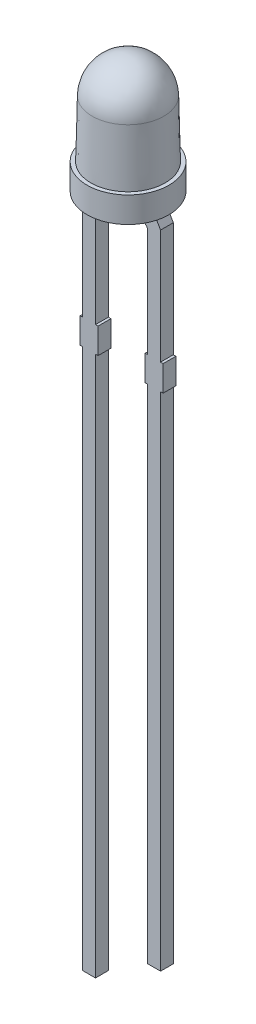
from build123d import *

# Parameters (mm, degrees)
SKETCH1_W          = 1.6
SKETCH1_H          = 1
EXTRUDE1_DEPTH     = 0.25
FILLET1_R          = 0.2
CUT_EXTRUDE1_DEPTH = 0.01


with BuildPart() as part:
    # Sketch1 → Revolve1 (revolve)
    with BuildSketch(Plane.XY, mode=Mode.PRIVATE) as revolve1_sk:
        with Locations((0.8, 0.5)):
            Rectangle(SKETCH1_W, SKETCH1_H)
    revolve(revolve1_sk.sketch.rotate(Axis((0, 1, 0), (0, 1, 0)), 90), axis=Axis((0, 1, 0), (0, 1, 0)))  # turned: the seam where the file's is

    # Sketch1_3 → Revolve2 (revolve)
    with BuildSketch(Plane.XY, mode=Mode.PRIVATE) as revolve2_sk:
        with BuildLine():
            Line((0, 4.6), (0, 1))
            Line((0, 1), (1.45, 1))
            Line((1.45, 1), (1.399643702, 3.231583349))
            ThreePointArc((1.399643702, 3.231583349), (0.978719396, 4.201053617), (0, 4.6))
        make_face()
    revolve(revolve2_sk.sketch.rotate(Axis((0, 1, 0), (0, 1, 0)), 90), axis=Axis((0, 1, 0), (0, 1, 0)))  # turned: the seam where the file's is

    # Sketch1_4 → Extrude1 (add, symmetric)
    with BuildSketch(Plane.XY):
        Polygon((1.27, 0), (0.42, 0), (0.42, -0.5), (1.02, -0.5), (1.02, -4.9), (0.92, -4.9), (0.92, -5.9), (1.02, -5.9), (1.02, -25.5), (1.52, -25.5), (1.52, -5.9), (1.62, -5.9), (1.62, -4.9), (1.52, -4.9), (1.52, -0.433012702), align=None)
        Polygon((-1.27, 0), (-1.52, -0.433012702), (-1.52, -4.9), (-1.62, -4.9), (-1.62, -5.9), (-1.52, -5.9), (-1.52, -27), (-1.02, -27), (-1.02, -5.9), (-0.92, -5.9), (-0.92, -4.9), (-1.02, -4.9), (-1.02, -0.5), (-0.42, -0.5), (-0.42, 0), align=None)
    extrude(amount=EXTRUDE1_DEPTH, both=True)

    # Fillet1
    fillet1_edges = [part.edges().sort_by_distance(p)[0] for p in [
        (1.02, -0.5, 0),
        (-1.02, -0.5, 0),
    ]]
    fillet(fillet1_edges, radius=FILLET1_R)

    # Sketch2 → Cut-Extrude1 (cut)
    with BuildSketch(Plane.XZ):
        Polygon((-0.609959979, -0.858665099), (-0.634742416, -0.93313108), (-0.660236878, -0.93261684), (-0.674477384, -0.881746587), (-0.690557289, -0.931983928), (-0.716387985, -0.931430131), (-0.737847637, -0.855995004), (-0.712610295, -0.856529023), (-0.700861878, -0.908447536), (-0.68377327, -0.857122378), (-0.662491624, -0.857577283), (-0.648330232, -0.909555131), (-0.634643523, -0.858150859), align=None)
        Polygon((-0.475812322, -0.861481362), (-0.500594759, -0.935947343), (-0.526089221, -0.935433102), (-0.540329727, -0.884562849), (-0.556409633, -0.934800191), (-0.582240329, -0.934246394), (-0.603699981, -0.858811267), (-0.578462639, -0.859345286), (-0.566714221, -0.911263799), (-0.549625614, -0.85993864), (-0.528343968, -0.860393545), (-0.514182576, -0.912371394), (-0.500495867, -0.860967121), align=None)
        Polygon((-0.341664666, -0.864297625), (-0.366447103, -0.938763606), (-0.391941565, -0.938249365), (-0.406182071, -0.887379112), (-0.422261976, -0.937616454), (-0.448092672, -0.937062656), (-0.469552324, -0.86162753), (-0.444314982, -0.862161549), (-0.432566565, -0.914080061), (-0.415477957, -0.862754903), (-0.394196312, -0.863209808), (-0.380034919, -0.915187656), (-0.36634821, -0.863783384), align=None)
        Polygon((-0.302789952, -0.940116261), (-0.327750396, -0.93960202), (-0.327196598, -0.913375754), (-0.302236155, -0.913889995), align=None)
        with BuildLine():
            add(Edge.make_bspline(
                [(-0.197717758, -0.911049585), (-0.197782236, -0.91224581), (-0.197908918, -0.914596065), (-0.198573487, -0.918025605), (-0.199627114, -0.921272317), (-0.20106367, -0.924340316), (-0.202871036, -0.927233419), (-0.205102667, -0.929920168), (-0.207700807, -0.932435028), (-0.210673682, -0.934745096), (-0.213971897, -0.936808214), (-0.217549415, -0.938618021), (-0.221401879, -0.940128274), (-0.225542786, -0.941292086), (-0.229938541, -0.942238753), (-0.234616239, -0.942830126), (-0.239557674, -0.943152009), (-0.242937477, -0.94313765), (-0.244671872, -0.943130281)],
                knots=[0, 0, 0, 0, 0.902626255, 1.77341389, 2.625621169, 3.470867019, 4.322029356, 5.191012395, 6.098187291, 7.044037616, 8.024852535, 9.027688581, 10.063639126, 11.139989839, 12.268247324, 13.451727298, 14.692317139, 16, 16, 16, 16], degree=3))
            add(Edge.make_bspline(
                [(-0.244671872, -0.943130281), (-0.24666437, -0.943068119), (-0.250517629, -0.942947904), (-0.256093043, -0.942389353), (-0.261279139, -0.941655981), (-0.266090007, -0.940576415), (-0.270617421, -0.939316959), (-0.274949447, -0.937897639), (-0.279159699, -0.93639654), (-0.281873988, -0.935239113), (-0.283220132, -0.934665091)],
                knots=[0, 0, 0, 0, 1.203405388, 2.32724652, 3.381787046, 4.364159093, 5.302027002, 6.21856218, 7.116500868, 8, 8, 8, 8], degree=3))
            Line((-0.283220132, -0.934665091), (-0.28272567, -0.910832021))
            Line((-0.28272567, -0.910832021), (-0.279917125, -0.910891357))
            add(Edge.make_bspline(
                [(-0.279917125, -0.910891357), (-0.278589886, -0.911937762), (-0.275937594, -0.914028851), (-0.271634449, -0.916729081), (-0.267107649, -0.919098273), (-0.262380378, -0.921075796), (-0.257571373, -0.92263769), (-0.25280923, -0.923820056), (-0.248123936, -0.924584697), (-0.245017365, -0.924725957), (-0.243485163, -0.924795629)],
                knots=[0, 0, 0, 0, 1.021384829, 2.041087774, 3.066386267, 4.108115676, 5.135581984, 6.120851118, 7.073179481, 8, 8, 8, 8], degree=3))
            add(Edge.make_bspline(
                [(-0.243485163, -0.924795629), (-0.243063195, -0.924798103), (-0.242159738, -0.924803402), (-0.240715596, -0.924757454), (-0.239086167, -0.924681946), (-0.237331902, -0.924544609), (-0.235565984, -0.924369752), (-0.233918718, -0.924081442), (-0.23243575, -0.923771908), (-0.231529936, -0.923459297), (-0.231103834, -0.923312243)],
                knots=[0, 0, 0, 0, 0.808443433, 1.730920239, 2.767970038, 3.933466555, 5.10244901, 6.165709291, 7.137136634, 8, 8, 8, 8], degree=3))
            add(Edge.make_bspline(
                [(-0.231103834, -0.923312243), (-0.230625557, -0.923115789), (-0.229691479, -0.922732114), (-0.22839409, -0.922042928), (-0.227223764, -0.921281436), (-0.226181525, -0.920439281), (-0.225286557, -0.919427868), (-0.224655286, -0.918178199), (-0.224280257, -0.916707237), (-0.224215673, -0.915660311), (-0.224181366, -0.915104173)],
                knots=[0, 0, 0, 0, 1.072964233, 2.09550425, 3.044592356, 3.968169394, 4.870818602, 5.825810278, 6.845047034, 8, 8, 8, 8], degree=3))
            add(Edge.make_bspline(
                [(-0.224181366, -0.915104173), (-0.224202738, -0.914573245), (-0.224244813, -0.91352799), (-0.224744797, -0.912006882), (-0.225630302, -0.910627571), (-0.226838592, -0.909348567), (-0.228388348, -0.908207917), (-0.230247355, -0.907176002), (-0.232435299, -0.906291159), (-0.234025924, -0.905844963), (-0.234861746, -0.905610502)],
                knots=[0, 0, 0, 0, 0.82308457, 1.620432243, 2.453727675, 3.352874885, 4.340918783, 5.432996612, 6.651123416, 8, 8, 8, 8], degree=3))
            add(Edge.make_bspline(
                [(-0.234861746, -0.905610502), (-0.236770642, -0.90512886), (-0.240688567, -0.904140313), (-0.246664602, -0.902905728), (-0.25261407, -0.901537722), (-0.25643538, -0.900260415), (-0.258299246, -0.899637401)],
                knots=[0, 0, 0, 0, 0.976031335, 2.003260101, 3.026078686, 4, 4, 4, 4], degree=3))
            add(Edge.make_bspline(
                [(-0.258299246, -0.899637401), (-0.259305489, -0.899272164), (-0.261264008, -0.89856128), (-0.264054855, -0.897348257), (-0.266634862, -0.89607463), (-0.268982382, -0.894686164), (-0.271094939, -0.893199022), (-0.273014475, -0.891656817), (-0.274707503, -0.890016583), (-0.276154364, -0.888259688), (-0.27741752, -0.886418537), (-0.278497588, -0.884483638), (-0.279429934, -0.882454015), (-0.280118188, -0.88030105), (-0.280713527, -0.878069269), (-0.28107579, -0.875722624), (-0.2812768, -0.873283041), (-0.28128014, -0.871624879), (-0.281281841, -0.870780597)],
                knots=[0, 0, 0, 0, 1.283776869, 2.498700329, 3.648104778, 4.733106613, 5.766444026, 6.744627296, 7.684133326, 8.588328419, 9.470112962, 10.358820773, 11.243685085, 12.14396387, 13.066542897, 14.011723146, 14.987634136, 16, 16, 16, 16], degree=3))
            add(Edge.make_bspline(
                [(-0.281281841, -0.870780597), (-0.281225889, -0.869649896), (-0.281115677, -0.867422688), (-0.28043944, -0.864181177), (-0.279410668, -0.861100096), (-0.277976201, -0.858190455), (-0.276129785, -0.855465365), (-0.273921908, -0.852901218), (-0.271320791, -0.850514323), (-0.268362578, -0.848323694), (-0.265120319, -0.846328317), (-0.261611968, -0.844636003), (-0.257904032, -0.843171541), (-0.253961996, -0.842053008), (-0.249824578, -0.84113987), (-0.24546423, -0.840568326), (-0.240886243, -0.840240057), (-0.237763148, -0.840254844), (-0.236167125, -0.840262401)],
                knots=[0, 0, 0, 0, 0.894291003, 1.761535864, 2.609149151, 3.458044758, 4.318600669, 5.206054204, 6.128633104, 7.104831714, 8.11366187, 9.135162331, 10.181984944, 11.262893009, 12.372649553, 13.530506242, 14.737993633, 16, 16, 16, 16], degree=3))
            add(Edge.make_bspline(
                [(-0.236167125, -0.840262401), (-0.234537814, -0.840318868), (-0.231280324, -0.840431763), (-0.226419872, -0.840888948), (-0.221598739, -0.841614456), (-0.21686045, -0.842531372), (-0.2122965, -0.843631014), (-0.208004433, -0.844848915), (-0.204034664, -0.846184776), (-0.201536854, -0.847205383), (-0.200328518, -0.84769911)],
                knots=[0, 0, 0, 0, 1.062843622, 2.124948057, 3.180945384, 4.240680951, 5.270812469, 6.240968977, 7.149053809, 8, 8, 8, 8], degree=3))
            Line((-0.200328518, -0.84769911), (-0.20082298, -0.870602591))
            Line((-0.20082298, -0.870602591), (-0.20355241, -0.870543255))
            add(Edge.make_bspline(
                [(-0.20355241, -0.870543255), (-0.204579737, -0.869732077), (-0.206677352, -0.868075798), (-0.210178662, -0.865914319), (-0.213997546, -0.86391505), (-0.218116955, -0.862140639), (-0.222413272, -0.860611936), (-0.226835819, -0.859500694), (-0.231312686, -0.85879174), (-0.234325265, -0.858648742), (-0.235830891, -0.858577274)],
                knots=[0, 0, 0, 0, 0.896218021, 1.829913157, 2.813883862, 3.847718201, 4.900600723, 5.934819858, 6.967864423, 8, 8, 8, 8], degree=3))
            add(Edge.make_bspline(
                [(-0.235830891, -0.858577274), (-0.236899661, -0.858573639), (-0.239034529, -0.858566376), (-0.242208374, -0.858856114), (-0.245353389, -0.859359937), (-0.247349755, -0.860050612), (-0.24835067, -0.860396895)],
                knots=[0, 0, 0, 0, 1.007148154, 2.011779898, 3.003168789, 4, 4, 4, 4], degree=3))
            add(Edge.make_bspline(
                [(-0.24835067, -0.860396895), (-0.248776129, -0.860566695), (-0.249621009, -0.860903885), (-0.250823742, -0.861554132), (-0.251906246, -0.862384249), (-0.252912494, -0.863287669), (-0.253757507, -0.864319111), (-0.254372838, -0.865452122), (-0.254773541, -0.866667116), (-0.254829495, -0.867507523), (-0.25485779, -0.867932496)],
                knots=[0, 0, 0, 0, 1.038806405, 2.062867993, 3.088784272, 4.125974695, 5.125612201, 6.095959068, 7.037173073, 8, 8, 8, 8], degree=3))
            add(Edge.make_bspline(
                [(-0.25485779, -0.867932496), (-0.254834729, -0.868556221), (-0.254790333, -0.869757003), (-0.254241499, -0.87145193), (-0.253288625, -0.872903399), (-0.252203495, -0.873926796), (-0.251105226, -0.874610006), (-0.250117963, -0.875146421), (-0.248951293, -0.875660383), (-0.247623199, -0.876164602), (-0.246123697, -0.876660722), (-0.244466281, -0.877148226), (-0.242643344, -0.877651588), (-0.241363537, -0.87794545), (-0.240696397, -0.878098635)],
                knots=[0, 0, 0, 0, 1.173960505, 2.260083397, 3.312830347, 4.422088842, 5.043414978, 5.750533976, 6.541484223, 7.447417928, 8.431199067, 9.521803768, 10.708163876, 12, 12, 12, 12], degree=3))
            add(Edge.make_bspline(
                [(-0.240696397, -0.878098635), (-0.238916275, -0.878513931), (-0.235433972, -0.87932634), (-0.230200719, -0.880548375), (-0.224865286, -0.881890562), (-0.221306236, -0.883078046), (-0.219454309, -0.883695945)],
                knots=[0, 0, 0, 0, 0.997986929, 1.952277346, 2.934482038, 4, 4, 4, 4], degree=3))
            add(Edge.make_bspline(
                [(-0.219454309, -0.883695945), (-0.218539827, -0.884027175), (-0.216750798, -0.884675169), (-0.214208399, -0.885819584), (-0.21182001, -0.886986592), (-0.209650655, -0.88828145), (-0.207650062, -0.889625809), (-0.205849875, -0.891067534), (-0.204239335, -0.892599359), (-0.202800724, -0.894206768), (-0.201550726, -0.89591654), (-0.200463947, -0.897731616), (-0.19958773, -0.899676889), (-0.198843684, -0.90172266), (-0.198293424, -0.903889519), (-0.197919838, -0.906172345), (-0.197723183, -0.908573665), (-0.197719593, -0.910211961), (-0.197717758, -0.911049585)],
                knots=[0, 0, 0, 0, 1.231889699, 2.409982638, 3.530705971, 4.598011493, 5.608183317, 6.582704366, 7.516266828, 8.421558806, 9.312085375, 10.196005457, 11.096815764, 12.011043338, 12.951123219, 13.924784649, 14.938989386, 16, 16, 16, 16], degree=3))
        make_face()
        with BuildLine():
            Line((-0.107134009, -0.944226689), (-0.131164863, -0.943712449))
            Line((-0.131164863, -0.943712449), (-0.130986857, -0.935425265))
            add(Edge.make_bspline(
                [(-0.130986857, -0.935425265), (-0.132088183, -0.936205711), (-0.134210252, -0.9377095), (-0.137380124, -0.939737903), (-0.140406966, -0.941453145), (-0.143317986, -0.942948313), (-0.146320346, -0.944061456), (-0.149522531, -0.944842945), (-0.152989717, -0.945244615), (-0.155385982, -0.945264639), (-0.156619768, -0.945274949)],
                knots=[0, 0, 0, 0, 1.154798459, 2.225102581, 3.217895131, 4.131076511, 5.021679709, 5.950613308, 6.944814984, 8, 8, 8, 8], degree=3))
            add(Edge.make_bspline(
                [(-0.156619768, -0.945274949), (-0.157623276, -0.94523261), (-0.159578396, -0.945150122), (-0.162416661, -0.944746106), (-0.165084285, -0.944145975), (-0.167558286, -0.943289119), (-0.16985617, -0.942239043), (-0.171975145, -0.940969322), (-0.173892355, -0.939451658), (-0.175656101, -0.93774502), (-0.177198943, -0.935804231), (-0.178504763, -0.933641446), (-0.179623432, -0.931293514), (-0.180511191, -0.928725257), (-0.181169851, -0.925947062), (-0.18165254, -0.922973737), (-0.181878991, -0.919790736), (-0.181877604, -0.917605115), (-0.181876888, -0.91647748)],
                knots=[0, 0, 0, 0, 1.102577318, 2.148135291, 3.144071761, 4.101269511, 5.01817895, 5.914791697, 6.807095825, 7.698076822, 8.605039245, 9.521548299, 10.467338951, 11.45664607, 12.499869506, 13.599851988, 14.761684478, 16, 16, 16, 16], degree=3))
            Line((-0.181876888, -0.91647748), (-0.180868186, -0.867683968))
            Line((-0.180868186, -0.867683968), (-0.156698882, -0.868198208))
            Line((-0.156698882, -0.868198208), (-0.157470243, -0.905381753))
            add(Edge.make_bspline(
                [(-0.157470243, -0.905381753), (-0.157488181, -0.906284938), (-0.157522616, -0.908018728), (-0.157496728, -0.910498166), (-0.157443367, -0.912747143), (-0.157338614, -0.914768315), (-0.157123766, -0.91660064), (-0.156793587, -0.918255856), (-0.156349657, -0.919760143), (-0.155931368, -0.920668015), (-0.155729736, -0.921105645)],
                knots=[0, 0, 0, 0, 1.358169666, 2.607195464, 3.727712924, 4.740544974, 5.649157093, 6.498695634, 7.276312967, 8, 8, 8, 8], degree=3))
            add(Edge.make_bspline(
                [(-0.155729736, -0.921105645), (-0.155514841, -0.921505638), (-0.155091305, -0.922293979), (-0.154182909, -0.923279574), (-0.153174735, -0.924160188), (-0.151942855, -0.924833804), (-0.150515195, -0.925378478), (-0.148832768, -0.925727962), (-0.146909826, -0.925992678), (-0.145538308, -0.926043259), (-0.144812015, -0.926070044)],
                knots=[0, 0, 0, 0, 0.85618062, 1.687437401, 2.520004869, 3.380721818, 4.328763296, 5.403627429, 6.625080676, 8, 8, 8, 8], degree=3))
            add(Edge.make_bspline(
                [(-0.144812015, -0.926070044), (-0.144284127, -0.926065937), (-0.143198958, -0.926057496), (-0.141532817, -0.925866781), (-0.139782699, -0.925545727), (-0.137320291, -0.924933764), (-0.134193452, -0.923856508), (-0.131878682, -0.922541135), (-0.130709958, -0.921877006)],
                knots=[0, 0, 0, 0, 0.637764771, 1.311040119, 2.023860089, 2.787359824, 4.377942957, 6, 6, 6, 6], degree=3))
            Line((-0.130709958, -0.921877006), (-0.129602363, -0.868752006))
            Line((-0.129602363, -0.868752006), (-0.105571509, -0.869266246))
            Line((-0.105571509, -0.869266246), (-0.107134009, -0.944226689))
        make_face()
        with BuildLine():
            Line((-0.009073993, -0.946272465), (-0.033243297, -0.945778003))
            Line((-0.033243297, -0.945778003), (-0.032471936, -0.908594459))
            add(Edge.make_bspline(
                [(-0.032471936, -0.908594459), (-0.032462994, -0.907084476), (-0.032445134, -0.904068677), (-0.032652743, -0.900346253), (-0.032953695, -0.897529984), (-0.033259967, -0.895703235), (-0.033654598, -0.894164824), (-0.034037783, -0.893275795), (-0.034212443, -0.892870566)],
                knots=[0, 0, 0, 0, 1.706663932, 3.408618783, 4.211047209, 4.906978926, 5.50178871, 6, 6, 6, 6], degree=3))
            add(Edge.make_bspline(
                [(-0.034212443, -0.892870566), (-0.034435293, -0.892471461), (-0.034877442, -0.891679608), (-0.035792507, -0.890676592), (-0.036828558, -0.88979623), (-0.038074049, -0.889126929), (-0.03949998, -0.888580565), (-0.041174775, -0.888225835), (-0.043091793, -0.887964288), (-0.044463243, -0.887913359), (-0.045189499, -0.887886389)],
                knots=[0, 0, 0, 0, 0.859141951, 1.704596215, 2.543353162, 3.411441021, 4.355665405, 5.41408119, 6.630616506, 8, 8, 8, 8], degree=3))
            add(Edge.make_bspline(
                [(-0.045189499, -0.887886389), (-0.046294476, -0.887915793), (-0.048548553, -0.887975774), (-0.051351517, -0.888631808), (-0.053637719, -0.889380196), (-0.055443698, -0.89012425), (-0.057326267, -0.891013535), (-0.058583077, -0.891703355), (-0.059232221, -0.892059649)],
                knots=[0, 0, 0, 0, 1.339139516, 2.731754846, 3.473410453, 4.25972406, 5.101144918, 6, 6, 6, 6], degree=3))
            Line((-0.059232221, -0.892059649), (-0.060339816, -0.945204427))
            Line((-0.060339816, -0.945204427), (-0.08437067, -0.944709965))
            Line((-0.08437067, -0.944709965), (-0.08280817, -0.869749522))
            Line((-0.08280817, -0.869749522), (-0.058777316, -0.870243984))
            Line((-0.058777316, -0.870243984), (-0.058955322, -0.878511389))
            add(Edge.make_bspline(
                [(-0.058955322, -0.878511389), (-0.057889437, -0.877734), (-0.055815479, -0.876221387), (-0.052647668, -0.874225531), (-0.049553644, -0.872522516), (-0.046518275, -0.871051172), (-0.043415517, -0.869924836), (-0.04018039, -0.86914528), (-0.036788161, -0.868733102), (-0.034477196, -0.868711992), (-0.033302632, -0.868701262)],
                knots=[0, 0, 0, 0, 1.129189459, 2.197134058, 3.202559493, 4.151856839, 5.082051886, 6.022532794, 6.994939007, 8, 8, 8, 8], degree=3))
            add(Edge.make_bspline(
                [(-0.033302632, -0.868701262), (-0.032319281, -0.868746368), (-0.030398674, -0.868834464), (-0.027601939, -0.869202122), (-0.024980227, -0.869817337), (-0.022527104, -0.870649035), (-0.020250039, -0.87170141), (-0.018125543, -0.872945652), (-0.016201164, -0.874450698), (-0.014429756, -0.876149061), (-0.012866627, -0.878077552), (-0.011500494, -0.880215541), (-0.01039181, -0.88258454), (-0.009438782, -0.88514282), (-0.008792129, -0.887937791), (-0.008315241, -0.890924146), (-0.008055746, -0.894131767), (-0.008062037, -0.896337971), (-0.008065291, -0.897478952)],
                knots=[0, 0, 0, 0, 1.082638398, 2.11452756, 3.097945572, 4.040615671, 4.959005956, 5.853339568, 6.742629988, 7.640251387, 8.547577713, 9.467084233, 10.424070547, 11.41984738, 12.464755664, 13.573676974, 14.745179908, 16, 16, 16, 16], degree=3))
            Line((-0.008065291, -0.897478952), (-0.009073993, -0.946272465))
        make_face()
        Polygon((0.086098364, -0.948278684), (0.01440137, -0.946775519), (0.016478111, -0.847388652), (0.042111022, -0.847922671), (0.040429851, -0.928084855), (0.086493934, -0.929054), align=None)
        Polygon((0.17361868, -0.950111911), (0.101723902, -0.948608747), (0.103800642, -0.84922188), (0.17569542, -0.850725044), (0.175280072, -0.869949728), (0.128899534, -0.868980582), (0.128543522, -0.886128525), (0.171581496, -0.887038335), (0.171185927, -0.906263019), (0.128147952, -0.905353209), (0.127633712, -0.929918082), (0.17401425, -0.930887228), align=None)
        with BuildLine():
            add(Edge.make_bspline(
                [(0.29033064, -0.902928456), (0.290295007, -0.904070236), (0.290224587, -0.906326675), (0.289822019, -0.909658718), (0.289290681, -0.912908361), (0.288503755, -0.916054201), (0.287559974, -0.919110107), (0.286415562, -0.922070651), (0.285033044, -0.924918514), (0.283507821, -0.927681222), (0.281799351, -0.930289661), (0.280024587, -0.932780672), (0.278127782, -0.935093213), (0.276114545, -0.937234864), (0.274028434, -0.9392387), (0.271818337, -0.941066018), (0.269510038, -0.942729001), (0.267895151, -0.943715074), (0.267090924, -0.944206146)],
                knots=[0, 0, 0, 0, 1.107228602, 2.18815579, 3.2518343, 4.298507113, 5.329797545, 6.352031354, 7.372904746, 8.397514941, 9.410106715, 10.394866835, 11.362459328, 12.307829909, 13.243902106, 14.165629206, 15.086468964, 16, 16, 16, 16], degree=3))
            add(Edge.make_bspline(
                [(0.267090924, -0.944206146), (0.265850822, -0.944884835), (0.263367097, -0.946244139), (0.259394545, -0.947822005), (0.255279067, -0.949121116), (0.250947129, -0.950066478), (0.246346296, -0.95073549), (0.241386357, -0.951153245), (0.236034085, -0.951379298), (0.232333714, -0.951331381), (0.230421621, -0.951306621)],
                knots=[0, 0, 0, 0, 0.895965141, 1.794473967, 2.705805824, 3.631144562, 4.603448383, 5.652979112, 6.787223929, 8, 8, 8, 8], degree=3))
            Line((0.230421621, -0.951306621), (0.195374152, -0.950574817))
            Line((0.195374152, -0.950574817), (0.197450893, -0.85118795))
            Line((0.197450893, -0.85118795), (0.233507064, -0.851939532))
            add(Edge.make_bspline(
                [(0.233507064, -0.851939532), (0.235459662, -0.852005808), (0.239232056, -0.852133853), (0.244677856, -0.852634457), (0.249709191, -0.853341155), (0.254323274, -0.85434118), (0.258557389, -0.855537166), (0.262421444, -0.856966557), (0.26595231, -0.858563858), (0.268090915, -0.859856785), (0.269128108, -0.860483836)],
                knots=[0, 0, 0, 0, 1.26440219, 2.442808357, 3.538197313, 4.550992963, 5.496514877, 6.383593657, 7.216065462, 8, 8, 8, 8], degree=3))
            add(Edge.make_bspline(
                [(0.269128108, -0.860483836), (0.269960233, -0.861039639), (0.271608645, -0.862140665), (0.273931603, -0.86398329), (0.276132167, -0.865936642), (0.278186256, -0.868032394), (0.280096857, -0.870258523), (0.281856036, -0.872624955), (0.283505778, -0.875110424), (0.284982946, -0.877745876), (0.286313478, -0.88049638), (0.287462114, -0.883362997), (0.288409076, -0.886346574), (0.289187523, -0.889435921), (0.289751395, -0.892649735), (0.290151396, -0.895976832), (0.290347689, -0.899418629), (0.290336373, -0.901748149), (0.29033064, -0.902928456)],
                knots=[0, 0, 0, 0, 0.965911533, 1.9134384, 2.86030207, 3.805666486, 4.744751056, 5.690758301, 6.651284216, 7.623323138, 8.605647596, 9.599844156, 10.602463595, 11.626143852, 12.673850451, 13.750911749, 14.860445587, 16, 16, 16, 16], degree=3))
        make_face()
        with BuildLine():
            add(Edge.make_bspline(
                [(0.263827475, -0.902176874), (0.263822469, -0.900599472), (0.263812774, -0.897544885), (0.26323324, -0.893129368), (0.262209289, -0.889055327), (0.26096879, -0.885909427), (0.259718762, -0.883599821), (0.258670363, -0.881965612), (0.257471874, -0.880436063), (0.256148126, -0.878995847), (0.254698929, -0.877639476), (0.253102259, -0.876395982), (0.25138601, -0.875217953), (0.250153418, -0.874536365), (0.249527633, -0.874190323)],
                knots=[0, 0, 0, 0, 1.704326833, 3.300372677, 4.801156171, 6.237469175, 6.942394617, 7.63843264, 8.334324622, 9.040690452, 9.751896057, 10.477812454, 11.227187639, 12, 12, 12, 12], degree=3))
            add(Edge.make_bspline(
                [(0.249527633, -0.874190323), (0.248878553, -0.8738728), (0.247591567, -0.873243221), (0.245609716, -0.872439433), (0.24358454, -0.871839601), (0.241461756, -0.871333791), (0.23905965, -0.870982759), (0.236227051, -0.870723155), (0.232877249, -0.870496018), (0.230468211, -0.870441751), (0.229175576, -0.870412633)],
                knots=[0, 0, 0, 0, 0.829310339, 1.64434217, 2.451076049, 3.251395865, 4.147196028, 5.23450512, 6.516098606, 8, 8, 8, 8], degree=3))
            Line((0.229175576, -0.870412633), (0.222688235, -0.870274184))
            Line((0.222688235, -0.870274184), (0.221402633, -0.932477507))
            Line((0.221402633, -0.932477507), (0.227889975, -0.932615956))
            add(Edge.make_bspline(
                [(0.227889975, -0.932615956), (0.228628342, -0.93263252), (0.230052225, -0.932664461), (0.232109413, -0.932656164), (0.234015197, -0.932646133), (0.2357624, -0.932582856), (0.237364506, -0.932502363), (0.238810015, -0.932413247), (0.240110376, -0.932276057), (0.241637845, -0.932035568), (0.243451691, -0.931655481), (0.24557354, -0.931016569), (0.247674783, -0.930205799), (0.249037484, -0.92954676), (0.249725418, -0.929214057)],
                knots=[0, 0, 0, 0, 1.188475977, 2.2918849, 3.310471471, 4.25527117, 5.105107573, 5.892015599, 6.585633689, 7.208360789, 8.379904345, 9.564823209, 10.770647372, 12, 12, 12, 12], degree=3))
            add(Edge.make_bspline(
                [(0.249725418, -0.929214057), (0.25084774, -0.928546643), (0.253052609, -0.927235466), (0.255947404, -0.924759049), (0.258345381, -0.921904341), (0.260315526, -0.918716708), (0.26182077, -0.915135798), (0.262912287, -0.911173509), (0.263637558, -0.906810599), (0.263762501, -0.903762167), (0.263827475, -0.902176874)],
                knots=[0, 0, 0, 0, 0.9744086, 1.914284665, 2.830138, 3.750234326, 4.703684098, 5.722078373, 6.815399931, 8, 8, 8, 8], degree=3))
        make_face(mode=Mode.SUBTRACT)
        Polygon((0.333778644, -0.953480224), (0.308818201, -0.952965983), (0.309371998, -0.926739717), (0.334332441, -0.927253958), align=None)
        with BuildLine():
            add(Edge.make_bspline(
                [(0.396307325, -0.956790921), (0.394710295, -0.956734433), (0.391573785, -0.956623491), (0.386988893, -0.956075444), (0.382610032, -0.955274171), (0.378461819, -0.954170002), (0.374538846, -0.95278531), (0.370917969, -0.951014128), (0.367504939, -0.949025813), (0.365474116, -0.947395937), (0.364463971, -0.946585225)],
                knots=[0, 0, 0, 0, 1.124407398, 2.208295305, 3.246807373, 4.255390292, 5.227152154, 6.169470222, 7.089482085, 8, 8, 8, 8], degree=3))
            add(Edge.make_bspline(
                [(0.364463971, -0.946585225), (0.36352464, -0.945724145), (0.361644632, -0.944000751), (0.359226796, -0.940998819), (0.357171233, -0.937685591), (0.355407313, -0.934094733), (0.354064452, -0.93017423), (0.353150039, -0.925946436), (0.352594162, -0.921415669), (0.352595957, -0.918290463), (0.352596882, -0.916680162)],
                knots=[0, 0, 0, 0, 0.917881846, 1.837080093, 2.768345609, 3.725144409, 4.715922096, 5.748257848, 6.839761443, 8, 8, 8, 8], degree=3))
            add(Edge.make_bspline(
                [(0.352596882, -0.916680162), (0.352664914, -0.914988792), (0.352796651, -0.911713617), (0.353601176, -0.907008223), (0.354731507, -0.902651732), (0.356384239, -0.898689785), (0.358390332, -0.895061544), (0.360749683, -0.891766989), (0.363454668, -0.888795902), (0.365510204, -0.887107373), (0.366540712, -0.886260858)],
                knots=[0, 0, 0, 0, 1.170411963, 2.266391581, 3.296916704, 4.279026226, 5.228802888, 6.160787502, 7.077942824, 8, 8, 8, 8], degree=3))
            add(Edge.make_bspline(
                [(0.366540712, -0.886260858), (0.367595568, -0.885528148), (0.369714561, -0.884056281), (0.37315072, -0.882214274), (0.376825592, -0.880733338), (0.380693508, -0.879554546), (0.384711956, -0.878681841), (0.388820128, -0.878058476), (0.392999121, -0.87774344), (0.395805822, -0.877738711), (0.397217136, -0.877736332)],
                knots=[0, 0, 0, 0, 0.95054997, 1.909463334, 2.879534484, 3.880264368, 4.900162657, 5.92203382, 6.955121097, 8, 8, 8, 8], degree=3))
            add(Edge.make_bspline(
                [(0.397217136, -0.877736332), (0.398470879, -0.877779033), (0.400938006, -0.877863061), (0.404550012, -0.87827112), (0.40801497, -0.878853934), (0.411319125, -0.879673814), (0.414487207, -0.88066466), (0.417560789, -0.881704923), (0.42049089, -0.882950077), (0.422385163, -0.883854293), (0.423324731, -0.884302788)],
                knots=[0, 0, 0, 0, 1.108563749, 2.181440333, 3.210476375, 4.212657115, 5.187887357, 6.144480461, 7.07965385, 8, 8, 8, 8], degree=3))
            Line((0.423324731, -0.884302788), (0.422889604, -0.904793294))
            Line((0.422889604, -0.904793294), (0.419487705, -0.904714181))
            add(Edge.make_bspline(
                [(0.419487705, -0.904714181), (0.418987027, -0.904272019), (0.417894062, -0.903306795), (0.416118338, -0.90175651), (0.413960722, -0.900106437), (0.41230072, -0.899137565), (0.411418085, -0.898622408)],
                knots=[0, 0, 0, 0, 0.790851961, 1.726405259, 2.791113354, 4, 4, 4, 4], degree=3))
            add(Edge.make_bspline(
                [(0.411418085, -0.898622408), (0.410479147, -0.898124907), (0.408558625, -0.897107308), (0.405958654, -0.896180575), (0.40372905, -0.895556464), (0.401892427, -0.895242512), (0.399926986, -0.894985451), (0.398569599, -0.894944793), (0.397869825, -0.894923832)],
                knots=[0, 0, 0, 0, 1.345853289, 2.752834114, 3.488944796, 4.279260109, 5.112907922, 6, 6, 6, 6], degree=3))
            add(Edge.make_bspline(
                [(0.397869825, -0.894923832), (0.397091021, -0.894919749), (0.395574712, -0.8949118), (0.393364641, -0.895188208), (0.391290393, -0.895612443), (0.389339213, -0.896223721), (0.387539854, -0.897062208), (0.385859147, -0.898079796), (0.384306863, -0.899283321), (0.382927841, -0.900705315), (0.381670944, -0.902268299), (0.380592877, -0.903994908), (0.379647735, -0.905850713), (0.378889385, -0.907849966), (0.378260669, -0.909982695), (0.377848027, -0.91226507), (0.377536683, -0.914681217), (0.377471868, -0.916342896), (0.377438655, -0.917194402)],
                knots=[0, 0, 0, 0, 1.089506183, 2.121237324, 3.111622464, 4.051723861, 4.976976411, 5.884183502, 6.798315937, 7.718766266, 8.651587001, 9.60178761, 10.563754754, 11.563262533, 12.591684183, 13.672590882, 14.807348693, 16, 16, 16, 16], degree=3))
            add(Edge.make_bspline(
                [(0.377438655, -0.917194402), (0.377439545, -0.918071655), (0.377441267, -0.919769359), (0.377645458, -0.922241106), (0.377990255, -0.92455835), (0.37851629, -0.926721347), (0.379242988, -0.928715078), (0.380096771, -0.930566073), (0.381167501, -0.932238017), (0.38236533, -0.933770245), (0.383740161, -0.935119466), (0.385261899, -0.936297358), (0.386921232, -0.937312845), (0.388743415, -0.938118342), (0.390690616, -0.938770331), (0.3927728, -0.939272552), (0.395007544, -0.939560895), (0.396543899, -0.939628111), (0.397335806, -0.939662756)],
                knots=[0, 0, 0, 0, 1.229822191, 2.380015792, 3.474494072, 4.512737354, 5.495398825, 6.446632064, 7.364943793, 8.273193452, 9.168885513, 10.058448528, 10.967027544, 11.88984299, 12.845916686, 13.843856958, 14.888625362, 16, 16, 16, 16], degree=3))
            add(Edge.make_bspline(
                [(0.397335806, -0.939662756), (0.398074561, -0.939667148), (0.399514454, -0.939675709), (0.401620906, -0.939504603), (0.403619859, -0.939242598), (0.405500399, -0.938820222), (0.407244333, -0.938304577), (0.408848929, -0.937752835), (0.410310072, -0.937167744), (0.411203804, -0.936702987), (0.411635648, -0.936478421)],
                knots=[0, 0, 0, 0, 1.196785178, 2.332632846, 3.422152053, 4.461746903, 5.452474663, 6.36822433, 7.211539736, 8, 8, 8, 8], degree=3))
            add(Edge.make_bspline(
                [(0.411635648, -0.936478421), (0.41236228, -0.936049089), (0.413763666, -0.935221077), (0.415671975, -0.933815643), (0.417370434, -0.932380353), (0.418435599, -0.931411626), (0.418953686, -0.930940446)],
                knots=[0, 0, 0, 0, 1.100289006, 2.122023979, 3.086569557, 4, 4, 4, 4], degree=3))
            Line((0.418953686, -0.930940446), (0.422355585, -0.93101956))
            Line((0.422355585, -0.93101956), (0.421920458, -0.951529845))
            add(Edge.make_bspline(
                [(0.421920458, -0.951529845), (0.420961794, -0.951941631), (0.419042935, -0.952765862), (0.416083996, -0.9538325), (0.413065331, -0.954753883), (0.409977237, -0.955565531), (0.40677411, -0.956182266), (0.403424083, -0.956590755), (0.399916726, -0.95681459), (0.397527299, -0.956798921), (0.396307325, -0.956790921)],
                knots=[0, 0, 0, 0, 0.949302103, 1.900119634, 2.860373156, 3.820757862, 4.804415767, 5.826124892, 6.890080782, 8, 8, 8, 8], degree=3))
        make_face()
        with BuildLine():
            add(Edge.make_bspline(
                [(0.515692169, -0.919844154), (0.515631727, -0.921342645), (0.515513579, -0.924271817), (0.51491643, -0.928529192), (0.513981592, -0.932531469), (0.512745075, -0.936298066), (0.51113998, -0.939803886), (0.509202095, -0.94305334), (0.506962455, -0.9460692), (0.504362733, -0.948792818), (0.501474088, -0.951231357), (0.498307956, -0.95333867), (0.494879554, -0.955111116), (0.491177121, -0.95653349), (0.48721537, -0.957622088), (0.482987694, -0.958334296), (0.478504822, -0.958771878), (0.475424227, -0.958756388), (0.473840903, -0.958748426)],
                knots=[0, 0, 0, 0, 1.109794077, 2.169367882, 3.176905566, 4.149308098, 5.099404851, 6.025219483, 6.945769656, 7.874500368, 8.806304236, 9.739028076, 10.684285542, 11.657789947, 12.670222197, 13.720627701, 14.828477322, 16, 16, 16, 16], degree=3))
            add(Edge.make_bspline(
                [(0.473840903, -0.958748426), (0.472263355, -0.958688179), (0.469183202, -0.958570547), (0.464709444, -0.957972642), (0.460514062, -0.957045168), (0.456598008, -0.955800844), (0.452953196, -0.954237963), (0.449588286, -0.952338298), (0.446525136, -0.950075305), (0.443725853, -0.947529379), (0.441260363, -0.94468053), (0.439122261, -0.941580846), (0.43732071, -0.938254353), (0.435860833, -0.934681687), (0.434793811, -0.930867619), (0.434010302, -0.926828178), (0.433598394, -0.92254944), (0.433593961, -0.919620785), (0.433591694, -0.918123426)],
                knots=[0, 0, 0, 0, 1.167564411, 2.279661911, 3.334144293, 4.343052549, 5.315353521, 6.263455757, 7.195204065, 8.127424704, 9.057588318, 9.976336555, 10.908340206, 11.851321302, 12.825565913, 13.833907976, 14.892523015, 16, 16, 16, 16], degree=3))
            add(Edge.make_bspline(
                [(0.433591694, -0.918123426), (0.433649187, -0.916611319), (0.433761376, -0.913660646), (0.434398143, -0.909375645), (0.435311628, -0.905339175), (0.43657968, -0.901559624), (0.438184543, -0.898046506), (0.440116617, -0.894781873), (0.442404976, -0.891793233), (0.444999136, -0.889048223), (0.447902417, -0.886622625), (0.451083732, -0.884525777), (0.454518954, -0.882763657), (0.458215865, -0.881330414), (0.462179238, -0.880278309), (0.466384555, -0.879519499), (0.470853377, -0.879131315), (0.47391277, -0.87912401), (0.475482517, -0.879120262)],
                knots=[0, 0, 0, 0, 1.117997896, 2.181621216, 3.197265766, 4.174499058, 5.12328696, 6.04782619, 6.972981952, 7.900433245, 8.834686437, 9.763430471, 10.711717428, 11.683880734, 12.688931831, 13.738739304, 14.839767249, 16, 16, 16, 16], degree=3))
            add(Edge.make_bspline(
                [(0.475482517, -0.879120262), (0.477073389, -0.879187483), (0.48016667, -0.879318188), (0.484656362, -0.879925191), (0.488874564, -0.880813241), (0.492799592, -0.882086331), (0.496442027, -0.883667149), (0.499796453, -0.885576864), (0.502863335, -0.887825754), (0.505631706, -0.890399764), (0.508082385, -0.893253016), (0.510222597, -0.896342227), (0.512010323, -0.899678948), (0.513427161, -0.903269293), (0.514542978, -0.907073296), (0.515290129, -0.911121786), (0.515681625, -0.915405645), (0.515688596, -0.918340225), (0.515692169, -0.919844154)],
                knots=[0, 0, 0, 0, 1.176156744, 2.286911129, 3.343832236, 4.357651543, 5.330719528, 6.273443454, 7.204066461, 8.13488075, 9.06073448, 9.978373115, 10.906940538, 11.851475655, 12.825896588, 13.83211301, 14.888989198, 16, 16, 16, 16], degree=3))
        make_face()
        with BuildLine():
            add(Edge.make_bspline(
                [(0.485747548, -0.937447002), (0.486134669, -0.936960633), (0.486919984, -0.935973979), (0.487900883, -0.934322712), (0.488733976, -0.932524548), (0.489445843, -0.93054284), (0.489992316, -0.928281714), (0.490428109, -0.925679169), (0.490690292, -0.922683922), (0.490756145, -0.920556671), (0.490791061, -0.919428806)],
                knots=[0, 0, 0, 0, 0.780502675, 1.58333408, 2.406223001, 3.268424672, 4.224951544, 5.325541424, 6.582006078, 8, 8, 8, 8], degree=3))
            add(Edge.make_bspline(
                [(0.490791061, -0.919428806), (0.490805684, -0.918373645), (0.490833766, -0.916347239), (0.490641329, -0.913435779), (0.49034464, -0.910783424), (0.489870775, -0.908388725), (0.489246315, -0.906246911), (0.488558675, -0.904308196), (0.487683098, -0.902615686), (0.486990561, -0.901615117), (0.486657358, -0.901133711)],
                knots=[0, 0, 0, 0, 1.326569024, 2.547636448, 3.666529792, 4.681159993, 5.61275159, 6.470585491, 7.264148309, 8, 8, 8, 8], degree=3))
            add(Edge.make_bspline(
                [(0.486657358, -0.901133711), (0.486297887, -0.900696451), (0.485591468, -0.899837165), (0.484380258, -0.898716043), (0.48303637, -0.897814343), (0.48158073, -0.897129789), (0.480058244, -0.896604321), (0.478479831, -0.89619431), (0.476833492, -0.89596707), (0.475713834, -0.895904402), (0.475146282, -0.895872635)],
                knots=[0, 0, 0, 0, 1.034577591, 2.033109006, 3.006345836, 3.982566232, 4.966501559, 5.949179933, 6.960444911, 8, 8, 8, 8], degree=3))
            add(Edge.make_bspline(
                [(0.475146282, -0.895872635), (0.474578767, -0.895867516), (0.473480734, -0.895857611), (0.471876201, -0.896036315), (0.470365178, -0.896277767), (0.468925918, -0.896653198), (0.467546209, -0.89721491), (0.466223162, -0.898020277), (0.464910978, -0.899045858), (0.464113176, -0.899870366), (0.463694542, -0.900303015)],
                knots=[0, 0, 0, 0, 1.069386401, 2.069058386, 3.040016639, 3.953886043, 4.868262823, 5.838504296, 6.865787032, 8, 8, 8, 8], degree=3))
            add(Edge.make_bspline(
                [(0.463694542, -0.900303015), (0.463326722, -0.900762807), (0.462561466, -0.901719414), (0.461601326, -0.903389438), (0.46073421, -0.905289353), (0.459983304, -0.907439721), (0.459364022, -0.90985939), (0.458932663, -0.912568018), (0.45860584, -0.915564837), (0.458531597, -0.917660984), (0.458492801, -0.918756338)],
                knots=[0, 0, 0, 0, 0.722617755, 1.503421354, 2.358902278, 3.286377179, 4.298245702, 5.423602142, 6.653687784, 8, 8, 8, 8], degree=3))
            add(Edge.make_bspline(
                [(0.458492801, -0.918756338), (0.458488964, -0.919745454), (0.458481539, -0.921659231), (0.458640725, -0.924432777), (0.458933164, -0.927009045), (0.459355199, -0.929386519), (0.459946176, -0.931551775), (0.460683442, -0.933493117), (0.461512084, -0.935249041), (0.462235721, -0.936262742), (0.462586947, -0.936754755)],
                knots=[0, 0, 0, 0, 1.263888756, 2.445416361, 3.548029671, 4.575969682, 5.528525333, 6.411138963, 7.228826321, 8, 8, 8, 8], degree=3))
            add(Edge.make_bspline(
                [(0.462586947, -0.936754755), (0.462947028, -0.93717214), (0.463658231, -0.937996524), (0.464872077, -0.939070105), (0.466192418, -0.939964078), (0.46760614, -0.940712351), (0.469150206, -0.941255151), (0.470790584, -0.941674126), (0.472547837, -0.941929862), (0.473754395, -0.941986634), (0.474374922, -0.942015831)],
                knots=[0, 0, 0, 0, 0.989223276, 1.953834973, 2.899660405, 3.847632667, 4.817751507, 5.831472878, 6.884736775, 8, 8, 8, 8], degree=3))
            add(Edge.make_bspline(
                [(0.474374922, -0.942015831), (0.475446857, -0.941980656), (0.477572357, -0.941910909), (0.480164133, -0.941274967), (0.482106695, -0.940468806), (0.483451208, -0.939654297), (0.484686192, -0.938650256), (0.485389105, -0.937853368), (0.485747548, -0.937447002)],
                knots=[0, 0, 0, 0, 1.51839626, 3.010768577, 3.752414409, 4.494944029, 5.232510793, 6, 6, 6, 6], degree=3))
        make_face(mode=Mode.SUBTRACT)
        with BuildLine():
            Line((0.606355869, -0.906026996), (0.605248274, -0.959171775))
            Line((0.605248274, -0.959171775), (0.58107897, -0.958677313))
            Line((0.58107897, -0.958677313), (0.581850331, -0.921236648))
            add(Edge.make_bspline(
                [(0.581850331, -0.921236648), (0.581866213, -0.920359838), (0.581896781, -0.918672234), (0.58189765, -0.916239072), (0.581857379, -0.914010425), (0.581790797, -0.911977646), (0.581637204, -0.910134282), (0.581394081, -0.908462948), (0.581008206, -0.906966449), (0.580627735, -0.906062882), (0.580446059, -0.905631427)],
                knots=[0, 0, 0, 0, 1.333463938, 2.566528021, 3.69952041, 4.722847323, 5.658607143, 6.510724599, 7.288866967, 8, 8, 8, 8], degree=3))
            add(Edge.make_bspline(
                [(0.580446059, -0.905631427), (0.580243113, -0.905245953), (0.579841311, -0.90448277), (0.578986515, -0.90351531), (0.578005913, -0.902684536), (0.576845111, -0.902021203), (0.575488817, -0.901511155), (0.573905816, -0.901108708), (0.572065294, -0.900894679), (0.57075503, -0.900836326), (0.570062356, -0.900805477)],
                knots=[0, 0, 0, 0, 0.860318456, 1.703307575, 2.537854893, 3.39817335, 4.336922655, 5.401387214, 6.626237484, 8, 8, 8, 8], degree=3))
            add(Edge.make_bspline(
                [(0.570062356, -0.900805477), (0.569475089, -0.900814897), (0.568302967, -0.900833699), (0.56655608, -0.901047314), (0.564835285, -0.901473748), (0.562621886, -0.902269426), (0.560012698, -0.903416178), (0.558037227, -0.90448484), (0.557087672, -0.904998515)],
                knots=[0, 0, 0, 0, 0.765553857, 1.527963743, 2.289015299, 3.072036511, 4.592609372, 6, 6, 6, 6], degree=3))
            Line((0.557087672, -0.904998515), (0.555980078, -0.958143294))
            Line((0.555980078, -0.958143294), (0.531949223, -0.957648832))
            Line((0.531949223, -0.957648832), (0.533511723, -0.882688389))
            Line((0.533511723, -0.882688389), (0.557542578, -0.883182851))
            Line((0.557542578, -0.883182851), (0.557364571, -0.891450256))
            add(Edge.make_bspline(
                [(0.557364571, -0.891450256), (0.558398474, -0.890694105), (0.56040681, -0.889225296), (0.563463588, -0.887267672), (0.566432756, -0.885562321), (0.569348334, -0.884076533), (0.572322842, -0.882895872), (0.575434705, -0.88211778), (0.578677107, -0.881638649), (0.580886065, -0.881626516), (0.582008559, -0.881620351)],
                knots=[0, 0, 0, 0, 1.135060183, 2.204831111, 3.215164635, 4.168983887, 5.103272638, 6.044316183, 7.006209353, 8, 8, 8, 8], degree=3))
            add(Edge.make_bspline(
                [(0.582008559, -0.881620351), (0.58321199, -0.881680641), (0.585559702, -0.881798259), (0.58895928, -0.88251002), (0.592127051, -0.883617804), (0.595058751, -0.885132011), (0.59772691, -0.887027799), (0.600065274, -0.889348919), (0.602115645, -0.892027842), (0.603155668, -0.894055822), (0.603685774, -0.895089496)],
                knots=[0, 0, 0, 0, 1.070479277, 2.088342202, 3.076929172, 4.04739923, 5.014087772, 5.976175981, 6.968443688, 8, 8, 8, 8], degree=3))
            add(Edge.make_bspline(
                [(0.603685774, -0.895089496), (0.604888518, -0.894145929), (0.607236827, -0.892303652), (0.610840792, -0.889845385), (0.614359112, -0.887668068), (0.617829641, -0.885841036), (0.621241177, -0.88433681), (0.624646312, -0.883341035), (0.628001122, -0.882690018), (0.630232163, -0.882662465), (0.63133609, -0.882648832)],
                knots=[0, 0, 0, 0, 1.186161846, 2.315932, 3.383943923, 4.395603791, 5.358411461, 6.271488477, 7.144726732, 8, 8, 8, 8], degree=3))
            add(Edge.make_bspline(
                [(0.63133609, -0.882648832), (0.632319641, -0.882691716), (0.634228497, -0.882774945), (0.636999334, -0.883168441), (0.639570137, -0.883808745), (0.641979892, -0.884623418), (0.644173635, -0.885732468), (0.64621696, -0.887010067), (0.648045521, -0.888548322), (0.649671126, -0.89030598), (0.651129813, -0.892254145), (0.652371226, -0.894414617), (0.653402568, -0.896771462), (0.654234914, -0.899321735), (0.654858716, -0.90207044), (0.655288283, -0.905012793), (0.655535038, -0.908145652), (0.655515466, -0.910298723), (0.655505394, -0.911406743)],
                knots=[0, 0, 0, 0, 1.102506701, 2.139721296, 3.128551265, 4.067579333, 4.982538578, 5.87586766, 6.7619617, 7.650361399, 8.55292473, 9.482787343, 10.435197812, 11.430187404, 12.483683668, 13.588809682, 14.759144734, 16, 16, 16, 16], degree=3))
            Line((0.655505394, -0.911406743), (0.654496691, -0.960200256))
            Line((0.654496691, -0.960200256), (0.630347166, -0.959705794))
            Line((0.630347166, -0.959705794), (0.631118527, -0.922265129))
            add(Edge.make_bspline(
                [(0.631118527, -0.922265129), (0.631131631, -0.921375126), (0.631156771, -0.919667702), (0.631194072, -0.917221417), (0.631137694, -0.914993093), (0.631098494, -0.912973761), (0.630967512, -0.911135686), (0.630723738, -0.909477469), (0.630332212, -0.907989362), (0.629954925, -0.907091463), (0.62977359, -0.906659908)],
                knots=[0, 0, 0, 0, 1.353636473, 2.596880646, 3.719953371, 4.743030932, 5.668073976, 6.520270093, 7.288801321, 8, 8, 8, 8], degree=3))
            add(Edge.make_bspline(
                [(0.62977359, -0.906659908), (0.629576194, -0.906275515), (0.629187787, -0.905519165), (0.628367726, -0.904533347), (0.627395037, -0.903686527), (0.626209867, -0.903033633), (0.624833409, -0.902509112), (0.623220177, -0.90215719), (0.62136333, -0.901885691), (0.620037199, -0.901851942), (0.619330552, -0.901833958)],
                knots=[0, 0, 0, 0, 0.847685406, 1.667947299, 2.504851529, 3.370207127, 4.314281469, 5.393188585, 6.610925039, 8, 8, 8, 8], degree=3))
            add(Edge.make_bspline(
                [(0.619330552, -0.901833958), (0.618336955, -0.901861654), (0.616335074, -0.901917453), (0.613861753, -0.902580496), (0.611844673, -0.903349499), (0.610159599, -0.904092309), (0.608298683, -0.904975127), (0.607025115, -0.905664656), (0.606355869, -0.906026996)],
                knots=[0, 0, 0, 0, 1.293186531, 2.605486558, 3.313271449, 4.110723589, 5.007206179, 6, 6, 6, 6], degree=3))
        make_face()
    extrude(amount=-CUT_EXTRUDE1_DEPTH, mode=Mode.SUBTRACT)


solid = part.part
